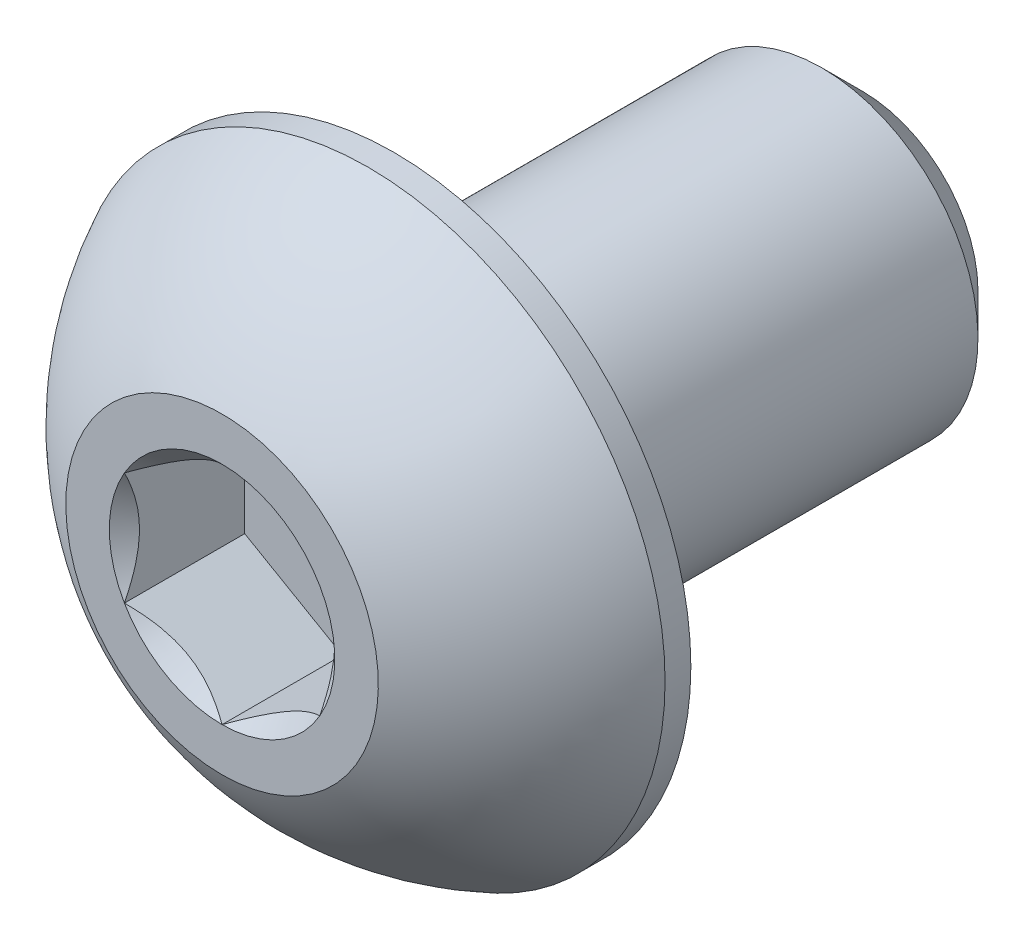
from build123d import *

# Parameters (mm, degrees)
SKETCH1_W          = 6
SKETCH1_H          = 2
CHAMFER1_SIZE      = 0.525
CUT_EXTRUDE2_DEPTH = 1.54


with BuildPart() as part:
    # Sketch1 → Revolve1 (revolve)
    with BuildSketch(Plane(origin=(0, 0, 0), x_dir=(0, 0, -1), z_dir=(1, 0, 0))):
        with Locations((5.2, 1)):
            Rectangle(SKETCH1_W, SKETCH1_H)
    revolve(axis=Axis((0, 0, -8.2), (0, 0, 1)))

    # Chamfer1
    chamfer1_edges = [part.edges().sort_by_distance(p)[0] for p in [
        (0, -2, -8.2),
    ]]
    chamfer(chamfer1_edges, length=CHAMFER1_SIZE)

    # Sketch7 → Revolve2 (revolve)
    with BuildSketch(Plane(origin=(0, 0, 0), x_dir=(0, 0, -1), z_dir=(1, 0, 0))):
        with BuildLine():
            Line((1.87, 3.8), (2.2, 3.8))
            Line((2.2, 3.8), (2.2, 0))
            Line((2.2, 0), (0, 0))
            Line((0, 0), (0, 2))
            ThreePointArc((0, 2), (0.793500147, 3.047002626), (1.87, 3.8))
        make_face()
    revolve(axis=Axis((0, 0, 0), (0, 0, -1)))

    # Sketch5 → Cut-Extrude2 (cut)
    with BuildSketch(Plane.XY):
        Polygon((1.25, -0.721687836), (1.25, 0.721687836), (0, 1.443375673), (-1.25, 0.721687836), (-1.25, -0.721687836), (0, -1.443375673), align=None)
    extrude(amount=-CUT_EXTRUDE2_DEPTH, mode=Mode.SUBTRACT)

    # Cut-Extrude3 cone 1 section (through the dimple's axis) → Cut-Extrude3 (revolve, cut)
    with BuildSketch(Plane(origin=(0, 0, 0), x_dir=(0, -1, 0), z_dir=(1, 0, 0))):
        Polygon((0, 0), (1.443375673, 0), (0, 1.443375673), align=None)
    revolve(axis=Axis((0, 0, 0), (0, 0, -1)), mode=Mode.SUBTRACT)


solid = part.part
